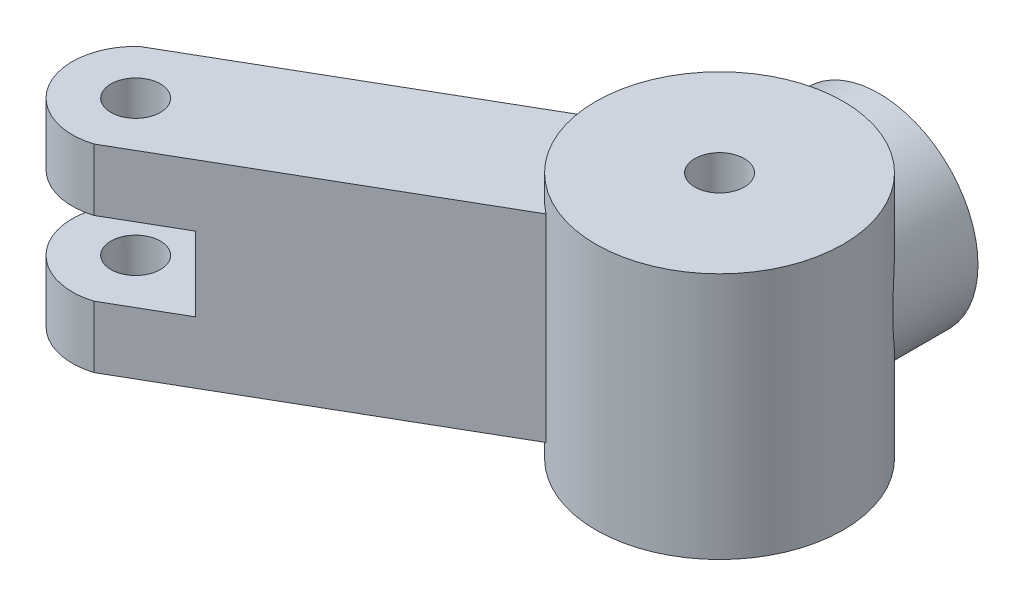
from build123d import *

# Parameters (mm, degrees)
SKETCH2_R                       = 4
SKETCH2_R_2                     = 2.5
BOSS_EXTRUDE1_DEPTH             = 4
SKETCH4_R                       = 5
BOSS_EXTRUDE2_DEPTH             = 10
SKETCH5_R                       = 2.5
CUT_EXTRUDE1_DEPTH              = 5
SKETCH6_R                       = 1
CUT_EXTRUDE2_DEPTH              = 11.0000001
SKETCH7_W                       = 8
SKETCH7_H                       = 5
BOSS_EXTRUDE3_DEPTH             = 15
BOSS_EXTRUDE3_DIRECTION_2_REACH = 14.552
SKETCH10_W                      = 5
SKETCH10_H                      = 3
CUT_EXTRUDE4_DEPTH              = 20
SKETCH9_R                       = 1
CUT_EXTRUDE6_DEPTH              = 20


with BuildPart() as part:
    # Sketch2 → Boss-Extrude1 (new body)
    with BuildSketch(Plane.XY):
        Circle(SKETCH2_R)
        Circle(SKETCH2_R_2, mode=Mode.SUBTRACT)
    extrude(amount=BOSS_EXTRUDE1_DEPTH)

    # Sketch4 → Boss-Extrude2 (add)
    with BuildSketch(Plane(origin=(0, 4.441770998, 4), x_dir=(1, 0, 0), z_dir=(0, 1, 0))):
        with Locations((0, -2.444351266)):
            Circle(SKETCH4_R)
    extrude(amount=-BOSS_EXTRUDE2_DEPTH)

    # Sketch5 → Cut-Extrude1 (cut)
    with BuildSketch(Plane.XY):
        Circle(SKETCH5_R)
    extrude(amount=CUT_EXTRUDE1_DEPTH, mode=Mode.SUBTRACT)

    # Sketch6 → Cut-Extrude2 (cut, through all)
    with BuildSketch(Plane(origin=(0, 4.441770998, 0), x_dir=(1, 0, 0), z_dir=(0, 1, 0))):
        with Locations((0, -6.444351266)):
            Circle(SKETCH6_R)
    extrude(amount=-CUT_EXTRUDE2_DEPTH, mode=Mode.SUBTRACT)

    # Sketch7 → Boss-Extrude3 (add)
    with BuildSketch(Plane(origin=(-7.120612972, 0, 4.111087816), x_dir=(0, 1, 0), z_dir=(-0.866025404, 0, 0.5))):
        with Locations((-0.558229002, -4.964101615)):
            Rectangle(SKETCH7_W, SKETCH7_H)
    extrude(amount=BOSS_EXTRUDE3_DEPTH)

    # Sketch7 → Boss-Extrude3 direction 2 (add, up to next)
    with BuildSketch(Plane(origin=(-7.120612972, 0, 4.111087816), x_dir=(0, 1, 0), z_dir=(-0.866025404, 0, 0.5)), mode=Mode.PRIVATE) as boss_extrude3_direction_2_sk1:
        with Locations((-0.558229002, -4.964101615)):
            Rectangle(SKETCH7_W, SKETCH7_H)
    boss_extrude3_direction_2_tool1 = extrude(boss_extrude3_direction_2_sk1.sketch, amount=-BOSS_EXTRUDE3_DIRECTION_2_REACH, mode=Mode.PRIVATE) - part.part
    add(boss_extrude3_direction_2_tool1.solids().sort_by_distance((-4.638562, -0.558229, 8.410126))[0])
    add(boss_extrude3_direction_2_tool1.solids().sort_by_distance((-4.638562, -0.558229, 8.410126))[1])

    # Sketch10 → Cut-Extrude4 (cut)
    with BuildSketch(Plane(origin=(1.232050808, 0, 2.133974596), x_dir=(-0.866025404, 0, 0.5), z_dir=(-0.5, 0, -0.866025404))):
        with Locations((20.722175633, -0.558229002)):
            Rectangle(SKETCH10_W, SKETCH10_H)
    extrude(amount=-CUT_EXTRUDE4_DEPTH, mode=Mode.SUBTRACT)

    # Sketch9 → Cut-Extrude6 (cut)
    with BuildSketch(Plane(origin=(0, 3.441770998, 0), x_dir=(1, 0, 0), z_dir=(0, 1, 0))):
        with BuildLine():
            Line((-18.878943222, -13.745062413), (-17.628943256, -15.910125863))
            ThreePointArc((-17.628943256, -15.910125863), (-17.943039978, -14.243046987), (-17.146892414, -12.745062413))
            Line((-17.146892414, -12.745062413), (-18.878943222, -13.745062413))
        make_face()
        with BuildLine():
            Line((-17.628943256, -15.910125863), (-16.378943222, -18.075189432))
            Line((-16.378943222, -18.075189432), (-14.646892414, -17.075189432))
            ThreePointArc((-14.646892414, -17.075189432), (-16.342258956, -17.015681135), (-17.628943256, -15.910125863))
        make_face()
        with Locations((-15.409753124, -14.628875922)):
            Circle(SKETCH9_R)
    extrude(amount=-CUT_EXTRUDE6_DEPTH, mode=Mode.SUBTRACT)


solid = part.part
